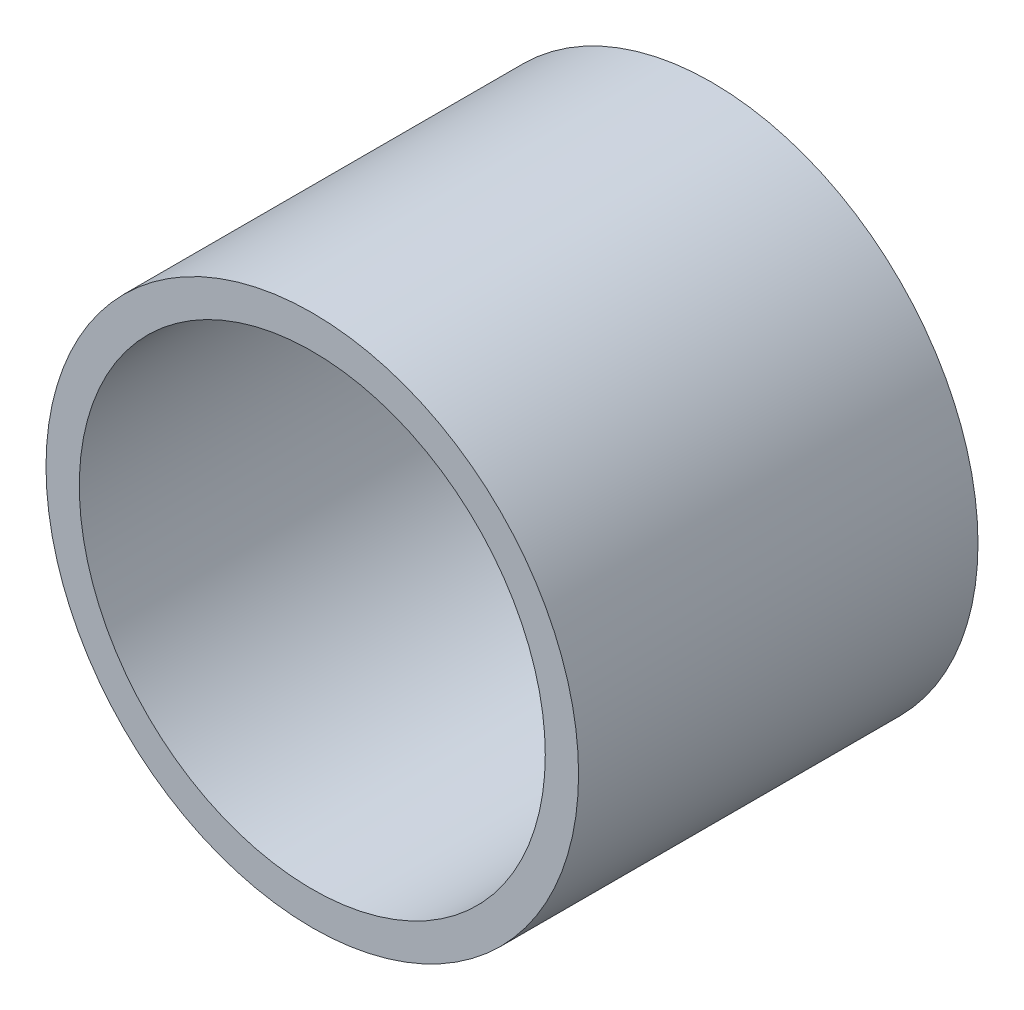
from build123d import *

# Parameters (mm, degrees)
SKETCH1_R           = 4
SKETCH1_R_2         = 3.5
BOSS_EXTRUDE1_DEPTH = 6


with BuildPart() as part:
    # Sketch1 → Boss-Extrude1 (new body)
    with BuildSketch(Plane.XY):
        Circle(SKETCH1_R)
        Circle(SKETCH1_R_2, mode=Mode.SUBTRACT)
    extrude(amount=BOSS_EXTRUDE1_DEPTH)


solid = part.part
